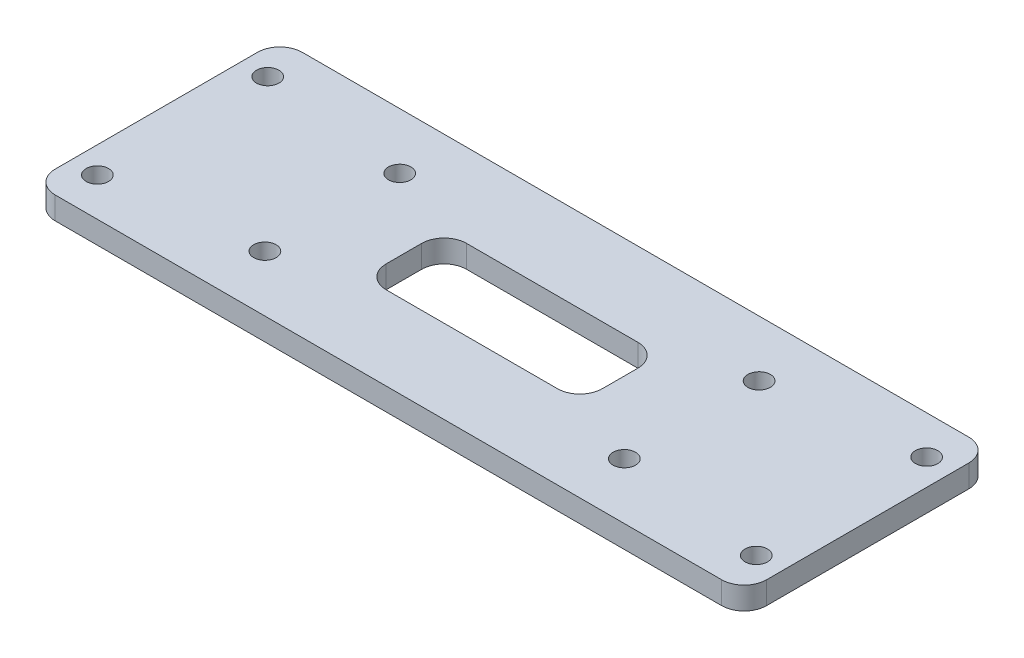
from build123d import *

# Parameters (mm, degrees)
SKETCH_1_W          = 95
SKETCH_1_H          = 33
EXTRUDE_1_DEPTH     = 3
SKETCH_2_R          = 1.5
CUT_EXTRUDE_1_DEPTH = 4
SKETCH_3_R          = 1.5
CUT_EXTRUDE_2_DEPTH = 4
FILLET_1_R          = 3
SKETCH_4_W          = 28.872486122
SKETCH_4_H          = 10.738590994
CUT_EXTRUDE_3_DEPTH = 4
FILLET_2_R          = 3


with BuildPart() as part:
    # 草图1 → 凸台-拉伸1 (new body)
    with BuildSketch(Plane(origin=(0, 0, 0), x_dir=(1, 0, 0), z_dir=(0, 1, 0))):
        Rectangle(SKETCH_1_W, SKETCH_1_H)
    extrude(amount=EXTRUDE_1_DEPTH)

    # 草图2 → 切除-拉伸1 (cut, through all)
    with BuildSketch(Plane(origin=(0, 3, 0), x_dir=(1, 0, 0), z_dir=(0, 1, 0))):
        with Locations((-44, 11.375)):
            Circle(SKETCH_2_R)
        with Locations((-44, -11.375)):
            Circle(SKETCH_2_R)
        with Locations((44, -11.375)):
            Circle(SKETCH_2_R)
        with Locations((44, 11.375)):
            Circle(SKETCH_2_R)
    extrude(amount=-CUT_EXTRUDE_1_DEPTH, mode=Mode.SUBTRACT)

    # 草图3 → 切除-拉伸2 (cut, through all)
    with BuildSketch(Plane(origin=(0, 3, 0), x_dir=(1, 0, 0), z_dir=(0, 1, 0))):
        with Locations((-24, 9)):
            Circle(SKETCH_3_R)
        with Locations((24, 9)):
            Circle(SKETCH_3_R)
        with Locations((-24, -9)):
            Circle(SKETCH_3_R)
        with Locations((24, -9)):
            Circle(SKETCH_3_R)
    extrude(amount=-CUT_EXTRUDE_2_DEPTH, mode=Mode.SUBTRACT)

    # 圆角1
    fillet_1_edges = [part.edges().sort_by_distance(p)[0] for p in [
        (-47.5, 1.5, -16.5),
        (47.5, 1.5, -16.5),
        (47.5, 1.5, 16.5),
        (-47.5, 1.5, 16.5),
    ]]
    fillet(fillet_1_edges, radius=FILLET_1_R)

    # 草图4 → 切除-拉伸3 (cut, through all)
    with BuildSketch(Plane(origin=(0, 3, 0), x_dir=(1, 0, 0), z_dir=(0, 1, 0))):
        Rectangle(SKETCH_4_W, SKETCH_4_H)
    extrude(amount=-CUT_EXTRUDE_3_DEPTH, mode=Mode.SUBTRACT)

    # 圆角2
    fillet_2_edges = [part.edges().sort_by_distance(p)[0] for p in [
        (-14.436243061, 1.5, 5.369295497),
        (-14.436243061, 1.5, -5.369295497),
        (14.436243061, 1.5, -5.369295497),
        (14.436243061, 1.5, 5.369295497),
    ]]
    fillet(fillet_2_edges, radius=FILLET_2_R)


solid = part.part
